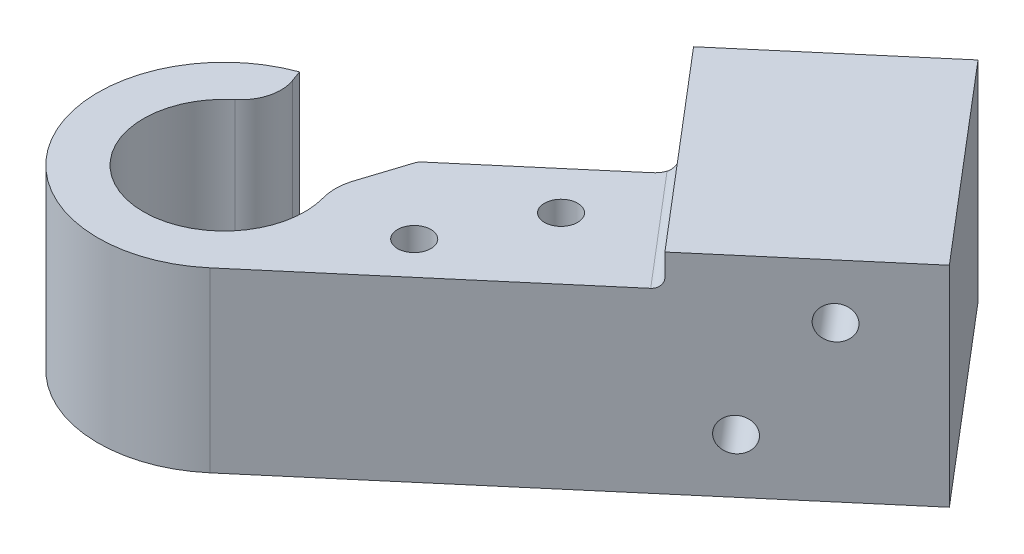
from build123d import *

# Parameters (mm, degrees)
SKETCH1_R                      = 12.5
BOSS_EXTRUDE1_DEPTH            = 17.6
SKETCH2_R                      = 6.875
CUT_EXTRUDE1_DEPTH             = 50.8
SKETCH3_R                      = 8
CUT_EXTRUDE3_DEPTH             = 15.6
CUT_EXTRUDE4_DEPTH             = 18.6
BOSS_EXTRUDE2_DEPTH            = 17.6
FILLET1_R                      = 4
SKETCH6_W                      = 25
SKETCH6_H                      = 20.775
BOSS_EXTRUDE3_DEPTH            = 20
M4X0_7_TAPPED_HOLE2_AT_2_COUNT = 2
M4X0_7_TAPPED_HOLE2_AT_2_PITCH = 12.206555616
M4X0_7_TAPPED_HOLE1_D          = 3.3
M4X0_7_TAPPED_HOLE1_DEPTH      = 7
M4X0_7_TAPPED_HOLE1_TIP        = 0.991420021
FILLET4_R                      = 1
FILLET6_R                      = 1
FILLET7_R                      = 2
CUT_EXTRUDE6_DEPTH             = 15.6
FILLET8_R                      = 5
BOSS_EXTRUDE4_DEPTH            = 17.6
FILLET11_R                     = 1


with BuildPart() as part:
    # Sketch1 → Boss-Extrude1 (new body)
    with BuildSketch(Plane(origin=(0, 0, 0), x_dir=(1, 0, 0), z_dir=(0, 1, 0))):
        Circle(SKETCH1_R)
    extrude(amount=BOSS_EXTRUDE1_DEPTH)

    # Sketch2 → Cut-Extrude1 (cut)
    with BuildSketch(Plane(origin=(0, 17.6, 0), x_dir=(1, 0, 0), z_dir=(0, 1, 0))):
        Circle(SKETCH2_R)
    extrude(amount=-CUT_EXTRUDE1_DEPTH, mode=Mode.SUBTRACT)

    # Sketch3 → Cut-Extrude3 (cut)
    with BuildSketch(Plane(origin=(0, 17.6, 0), x_dir=(1, 0, 0), z_dir=(0, 1, 0))):
        Circle(SKETCH3_R)
    extrude(amount=-CUT_EXTRUDE3_DEPTH, mode=Mode.SUBTRACT)

    # Sketch4 → Cut-Extrude4 (cut, through all)
    with BuildSketch(Plane(origin=(0, 17.6, 0), x_dir=(1, 0, 0), z_dir=(0, 1, 0))):
        with BuildLine():
            ThreePointArc((-2.736161147, 7.517540966), (2.405646396, 7.629735606), (6.553216354, 4.588611491))
            Line((6.553216354, 4.588611491), (10.239400554, 7.169705454))
            ThreePointArc((10.239400554, 7.169705454), (3.758822494, 11.921461884), (-4.275251792, 11.74615776))
            Line((-4.275251792, 11.74615776), (-2.736161147, 7.517540966))
        make_face()
    extrude(amount=-CUT_EXTRUDE4_DEPTH, mode=Mode.SUBTRACT)

    # Sketch5 → Boss-Extrude2 (add, through all)
    with BuildSketch(Plane(origin=(0, 17.6, 0), x_dir=(1, 0, 0), z_dir=(0, 1, 0))):
        with BuildLine():
            Line((8.100371818, -9.520187835), (32.472052675, 11.216764019))
            Line((32.472052675, 11.216764019), (23.399636239, 21.879374394))
            Line((23.399636239, 21.879374394), (10.717665156, 11.088759446))
            Line((10.717665156, 11.088759446), (10.239400554, 7.169705454))
            ThreePointArc((10.239400554, 7.169705454), (12.398586499, -1.589041484), (8.100371818, -9.520187835))
        make_face()
    extrude(amount=-BOSS_EXTRUDE2_DEPTH)

    # Fillet1
    fillet1_edges = [part.edges().sort_by_distance(p)[0] for p in [
        (-2.736161147, 9.8, -7.517540966),
    ]]
    fillet(fillet1_edges, radius=FILLET1_R)

    # Sketch6 → Boss-Extrude3 (add)
    with BuildSketch(Plane(origin=(24.371680857, 0, -20.736951854), x_dir=(-0.648029745, 0, -0.761615027), z_dir=(0.761615027, 0, -0.648029745))):
        with Locations((0, 10.3875)):
            Rectangle(SKETCH6_W, SKETCH6_H)
    extrude(amount=BOSS_EXTRUDE3_DEPTH)

    # Sketch9 → M4x0.7 Tapped Hole2 (revolve, cut)
    with BuildSketch(Plane(origin=(25.410689361, 15.3875, -38.033496634), x_dir=(-0.761615027, 0, 0.648029745), z_dir=(0, 1, 0))):
        Polygon((0, 0), (0, 7.991420021), (1.65, 7), (1.65, 0), align=None)
    m4x0_7_tapped_hole2 = revolve(axis=Axis((21.295700477, 15.3875, -42.869752054), (0.648029745, 0, 0.761615027)), mode=Mode.SUBTRACT)

    # M4x0.7 Tapped Hole2 at 2: M4x0.7 Tapped Hole2 ×2
    with Locations(*[Vector(-0.436757539, -0.819231921, 0.371620657) * (i * M4X0_7_TAPPED_HOLE2_AT_2_PITCH) for i in range(1, M4X0_7_TAPPED_HOLE2_AT_2_COUNT)]):
        add(m4x0_7_tapped_hole2, mode=Mode.SUBTRACT)

    # Mirror1: M4x0.7 Tapped Hole2 across plane
    add(m4x0_7_tapped_hole2.mirror(Plane(origin=(0, 0, 0), x_dir=(-0.761615027, 0, 0.648029745), z_dir=(-0.648029745, 0, -0.761615027))), mode=Mode.SUBTRACT)

    # Mirror1 copy 1 sketch → Mirror1 copy 1 (revolve, cut)
    with BuildSketch(Plane(origin=(36.280127809, 5.3875, -14.456912746), x_dir=(-0.761615027, 0, 0.648029745), z_dir=(0, 1, 0))):
        Polygon((0, 0), (0, -7.991420021), (1.65, -7), (1.65, 0), align=None)
    revolve(axis=Axis((40.395116693, 5.3875, -9.620657326), (0.648029745, 0, 0.761615027)), mode=Mode.SUBTRACT)

    # M4x0.7 Tapped Hole1
    with Locations(Plane(origin=(0, 17.6, 0), x_dir=(1, 0, 0), z_dir=(0, 1, 0))):
        with Locations((20.785019884, 12.607162838), (15.760988598, 3.080405276)):
            Hole(M4X0_7_TAPPED_HOLE1_D / 2, depth=M4X0_7_TAPPED_HOLE1_DEPTH)
            with Locations((0, 0, -(M4X0_7_TAPPED_HOLE1_DEPTH + M4X0_7_TAPPED_HOLE1_TIP / 2))):  # 118° drill point
                Cone(0, M4X0_7_TAPPED_HOLE1_D / 2, M4X0_7_TAPPED_HOLE1_TIP, mode=Mode.SUBTRACT)

    # Fillet4
    fillet4_edges = [part.edges().sort_by_distance(p)[0] for p in [
        (27.935844457, 17.6, -16.548069207),
    ]]
    fillet(fillet4_edges, radius=FILLET4_R)

    # Fillet6
    fillet6_edges = [part.edges().sort_by_distance(p)[0] for p in [
        (-2.736161147, 1, -7.517540966),
        (6.553216354, 1, -4.588611491),
    ]]
    fillet(fillet6_edges, radius=FILLET6_R)

    # Fillet7
    fillet7_edges = [part.edges().sort_by_distance(p)[0] for p in [
        (23.399636239, 8.8, -21.879374394),
    ]]
    fillet(fillet7_edges, radius=FILLET7_R)

    # Sketch13 → Cut-Extrude6 (cut)
    with BuildSketch(Plane(origin=(0, 17.6, 0), x_dir=(1, 0, 0), z_dir=(0, 1, 0))):
        Polygon((7.237831979, 3.407900857), (11.336580589, 16.160351586), (5.142300877, 6.128355545), (6.34884573, 4.867459081), align=None)
    extrude(amount=-CUT_EXTRUDE6_DEPTH, mode=Mode.SUBTRACT)

    # Fillet8
    fillet8_edges = [part.edges().sort_by_distance(p)[0] for p in [
        (7.237831979, 9.8, -3.407900857),
    ]]
    fillet(fillet8_edges, radius=FILLET8_R)

    # Sketch14 → Boss-Extrude4 (add)
    with BuildSketch(Plane(origin=(0, 17.6, 0), x_dir=(1, 0, 0), z_dir=(0, 1, 0))):
        Polygon((7.926350274, 5.550090213), (9.325919645, 9.904575236), (10.717665156, 11.088759446), (10.239400554, 7.169705454), align=None)
    extrude(amount=-BOSS_EXTRUDE4_DEPTH)

    # Fillet11
    fillet11_edges = [part.edges().sort_by_distance(p)[0] for p in [
        (9.325919645, 8.8, -9.904575236),
    ]]
    fillet(fillet11_edges, radius=FILLET11_R)


solid = part.part
